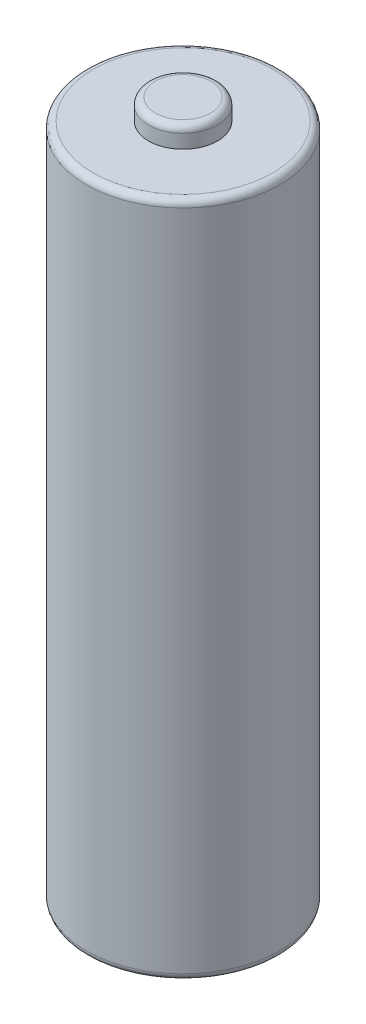
from build123d import *

# Parameters (mm, degrees)
SKETCH1_R           = 7
BOSS_EXTRUDE1_DEPTH = 49
SKETCH2_R           = 2.5
BOSS_EXTRUDE2_DEPTH = 1.5
FILLET1_R           = 0.5


with BuildPart() as part:
    # Sketch1 → Boss-Extrude1 (new body)
    with BuildSketch(Plane(origin=(0, 0, 0), x_dir=(1, 0, 0), z_dir=(0, 1, 0))):
        Circle(SKETCH1_R)
    extrude(amount=BOSS_EXTRUDE1_DEPTH)

    # Sketch2 → Boss-Extrude2 (add)
    with BuildSketch(Plane(origin=(0, 49, 0), x_dir=(1, 0, 0), z_dir=(0, 1, 0))):
        Circle(SKETCH2_R)
    extrude(amount=BOSS_EXTRUDE2_DEPTH)

    # Fillet1
    fillet1_edges = [part.edges().sort_by_distance(p)[0] for p in [
        (-7, 0, 0),
        (-7, 49, 0),
        (-2.5, 50.5, 0),
    ]]
    fillet(fillet1_edges, radius=FILLET1_R)


solid = part.part
